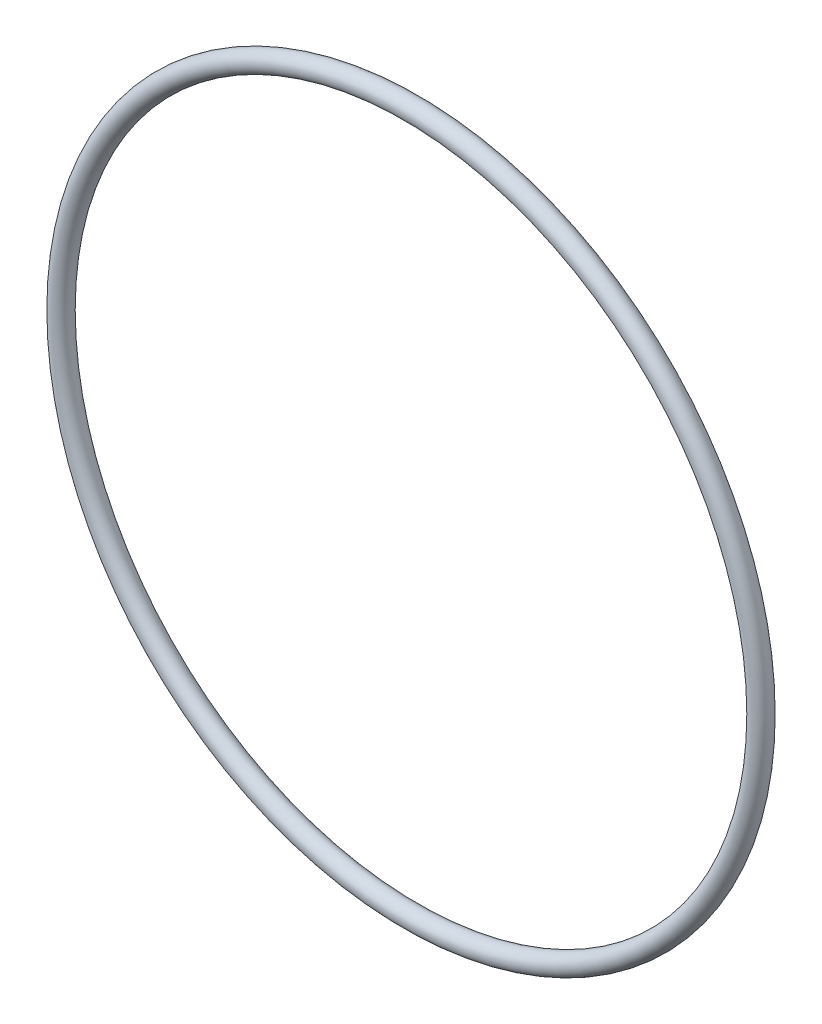
from build123d import *

# Parameters (mm, degrees)
SKETCH1_R = 1.3081


with BuildPart() as part:
    # Sketch1 → Revolve1 (revolve)
    with BuildSketch(Plane(origin=(0, 0, 0), x_dir=(0, -1, 0), z_dir=(1, 0, 0))):
        with Locations((45.593, 0)):
            Circle(SKETCH1_R)
    revolve(axis=Axis((0, 0, 1.3081), (0, 0, -1)))


solid = part.part
